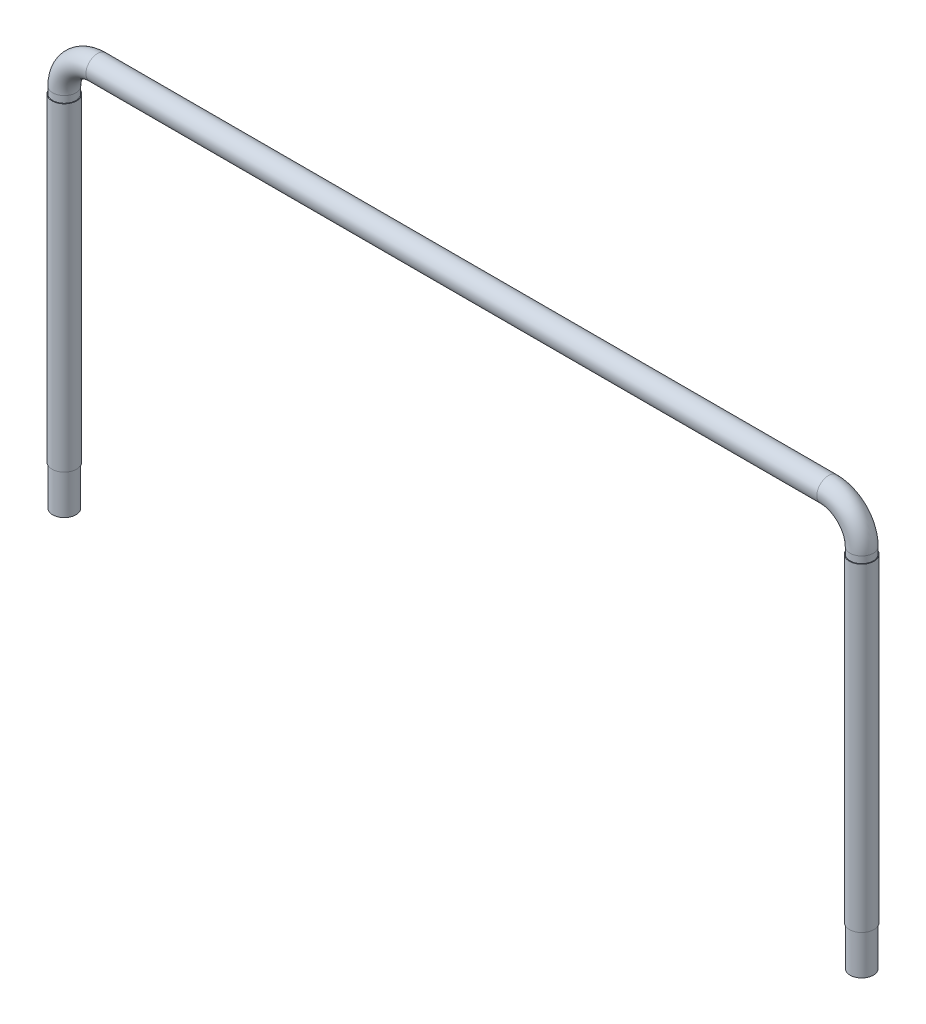
from build123d import *

# Parameters (mm, degrees)
SKETCH2_R           = 44.45
SKETCH3_R           = 46.99
BOSS_EXTRUDE1_DEPTH = 1219.2


with BuildPart() as part:
    # Sweep1: sweep along a path in Sketch1
    with BuildLine(Plane.XY) as sweep1_path:
        Line((-1524, 0), (-1524, 1397))
        ThreePointArc((-1524, 1397), (-1486.802561211, 1486.802561211), (-1397, 1524))
        Line((-1397, 1524), (1397, 1524))
        ThreePointArc((1397, 1524), (1486.802561211, 1486.802561211), (1524, 1397))
        Line((1524, 1397), (1524, 0))
    # Sketch2 → Sweep1 (sweep)
    with BuildSketch(Plane(origin=(0, 0, 0), x_dir=(1, 0, 0), z_dir=(0, 1, 0))):
        with Locations((-1524, 0)):
            Circle(SKETCH2_R)
    sweep(path=sweep1_path.line)

    # Sketch3 → Boss-Extrude1 (add)
    with BuildSketch(Plane(origin=(0, 152.4, 0), x_dir=(-1, 0, 0), z_dir=(0, -1, 0))):
        with Locations((-1524, 0)):
            Circle(SKETCH3_R)
        with Locations((1524, 0)):
            Circle(SKETCH3_R)
    extrude(amount=-BOSS_EXTRUDE1_DEPTH)


solid = part.part
